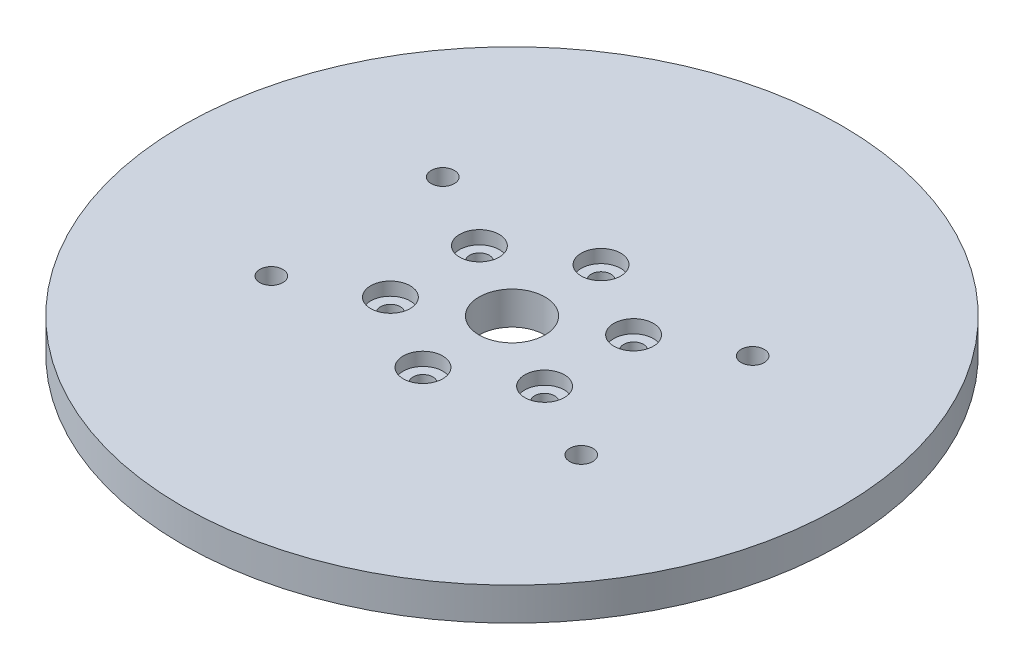
from build123d import *

# Parameters (mm, degrees)
SKETCH_1_R               = 50
SKETCH_1_R_2             = 1.75
SKETCH_1_R_3             = 5
EXTRUDE_1_DEPTH          = 5
SKETCH_2_R               = 1.5
CUT_EXTRUDE_1_DEPTH      = 2
SKETCH_3_R               = 3
CUT_EXTRUDE_2_DEPTH      = 71.887234394
CUT_EXTRUDE_2_DEPTH_BACK = 71.887234394
SKETCH_2_3_R             = 1.5
CUT_EXTRUDE_START        = -2
SKETCH_4_R               = 1.75
SKETCH_4_R_2             = 3
SKETCH_4_R_3             = 1.5
CUT_EXTRUDE_3_DEPTH      = 2


with BuildPart() as part:
    # Эскиз1 → Бобышка-Вытянуть1 (new body)
    with BuildSketch(Plane(origin=(0, 0, 0), x_dir=(1, 0, 0), z_dir=(0, 1, 0))):
        Circle(SKETCH_1_R)
        with Locations((-23.5, 13)):
            Circle(SKETCH_1_R_2, mode=Mode.SUBTRACT)
        with Locations((-23.5, -13)):
            Circle(SKETCH_1_R_2, mode=Mode.SUBTRACT)
        Circle(SKETCH_1_R_3, mode=Mode.SUBTRACT)
        with Locations((23.5, -13)):
            Circle(SKETCH_1_R_2, mode=Mode.SUBTRACT)
        with Locations((23.5, 13)):
            Circle(SKETCH_1_R_2, mode=Mode.SUBTRACT)
    extrude(amount=EXTRUDE_1_DEPTH)

    # Эскиз2 → Вырез-Вытянуть1 (cut)
    with BuildSketch(Plane.XZ):
        with Locations((0, 13.5)):
            Circle(SKETCH_2_R)
        with Locations((11.691342951, 6.75)):
            Circle(SKETCH_2_R)
        with Locations((11.691342951, -6.75)):
            Circle(SKETCH_2_R)
        with Locations((0, -13.5)):
            Circle(SKETCH_2_R)
        with Locations((-11.691342951, -6.75)):
            Circle(SKETCH_2_R)
        with Locations((-11.691342951, 6.75)):
            Circle(SKETCH_2_R)
        Polygon((-25.232050808, 16), (-26.964101615, 13), (-25.232050808, 10), (-21.767949192, 10), (-20.035898385, 13), (-21.767949192, 16), align=None)
        Polygon((21.767949192, 16), (20.035898385, 13), (21.767949192, 10), (25.232050808, 10), (26.964101615, 13), (25.232050808, 16), align=None)
        Polygon((21.767949192, -10), (20.035898385, -13), (21.767949192, -16), (25.232050808, -16), (26.964101615, -13), (25.232050808, -10), align=None)
        Polygon((-25.232050808, -10), (-26.964101615, -13), (-25.232050808, -16), (-21.767949192, -16), (-20.035898385, -13), (-21.767949192, -10), align=None)
    extrude(amount=-CUT_EXTRUDE_1_DEPTH, mode=Mode.SUBTRACT)

    # Эскиз3 → Вырез-Повернуть1 (revolve, cut)
    with BuildSketch(Plane.XY):
        with Locations((-45, -1.5)):
            Circle(SKETCH_3_R)
    revolve(axis=Axis((0, 0, 0), (0, -1, 0)), mode=Mode.SUBTRACT)

    # Эскиз2<3> → Вырез-Вытянуть2 (cut, two sides: drawn at the far end of the back side and taken through both)
    with BuildSketch(Plane.XZ.offset(-CUT_EXTRUDE_2_DEPTH_BACK)):
        with Locations((0, 13.5)):
            Circle(SKETCH_2_3_R)
        with Locations((11.691342951, 6.75)):
            Circle(SKETCH_2_3_R)
        with Locations((11.691342951, -6.75)):
            Circle(SKETCH_2_3_R)
        with Locations((0, -13.5)):
            Circle(SKETCH_2_3_R)
        with Locations((-11.691342951, -6.75)):
            Circle(SKETCH_2_3_R)
        with Locations((-11.691342951, 6.75)):
            Circle(SKETCH_2_3_R)
    extrude(amount=CUT_EXTRUDE_2_DEPTH + CUT_EXTRUDE_2_DEPTH_BACK, mode=Mode.SUBTRACT)

    # Эскиз4 → Вырез-Вытянуть3 (cut)
    # profile 1 of 7: a face of its own
    with BuildSketch(Plane(origin=(0, 5, 0), x_dir=(1, 0, 0), z_dir=(0, 1, 0)).offset(CUT_EXTRUDE_START)):
        with Locations((-23.5, -13)):
            Circle(SKETCH_4_R)
    # profile 2 of 7: a face of its own
    with BuildSketch(Plane(origin=(0, 5, 0), x_dir=(1, 0, 0), z_dir=(0, 1, 0)).offset(CUT_EXTRUDE_START)):
        with Locations((-11.691342951, 6.75)):
            Circle(SKETCH_4_R_2)
        with Locations((-11.691342951, 6.75)):
            Circle(SKETCH_4_R_3, mode=Mode.SUBTRACT)
    # profile 3 of 7: a face of its own
    with BuildSketch(Plane(origin=(0, 5, 0), x_dir=(1, 0, 0), z_dir=(0, 1, 0)).offset(CUT_EXTRUDE_START)):
        with Locations((0, 13.5)):
            Circle(SKETCH_4_R_2)
        with Locations((0, 13.5)):
            Circle(SKETCH_4_R_3, mode=Mode.SUBTRACT)
    # profile 4 of 7: a face of its own
    with BuildSketch(Plane(origin=(0, 5, 0), x_dir=(1, 0, 0), z_dir=(0, 1, 0)).offset(CUT_EXTRUDE_START)):
        with Locations((11.691342951, 6.75)):
            Circle(SKETCH_4_R_2)
    # profile 5 of 7: a face of its own
    with BuildSketch(Plane(origin=(0, 5, 0), x_dir=(1, 0, 0), z_dir=(0, 1, 0)).offset(CUT_EXTRUDE_START)):
        with Locations((11.691342951, -6.75)):
            Circle(SKETCH_4_R_2)
    # profile 6 of 7: a face of its own
    with BuildSketch(Plane(origin=(0, 5, 0), x_dir=(1, 0, 0), z_dir=(0, 1, 0)).offset(CUT_EXTRUDE_START)):
        with Locations((0, -13.5)):
            Circle(SKETCH_4_R_2)
    # profile 7 of 7: a face of its own
    with BuildSketch(Plane(origin=(0, 5, 0), x_dir=(1, 0, 0), z_dir=(0, 1, 0)).offset(CUT_EXTRUDE_START)):
        with Locations((-11.691342951, -6.75)):
            Circle(SKETCH_4_R_2)
    extrude(amount=CUT_EXTRUDE_3_DEPTH, mode=Mode.SUBTRACT)


solid = part.part
